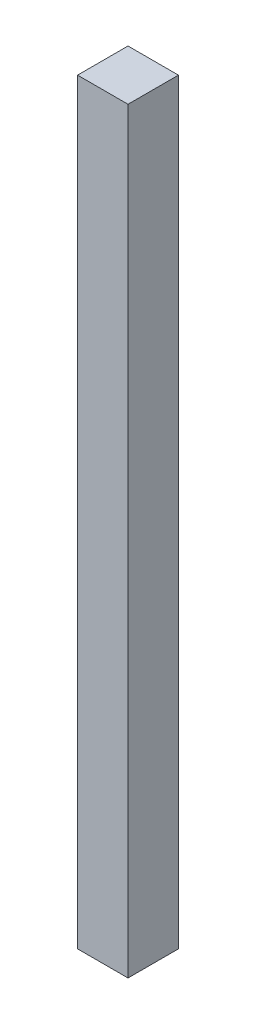
from build123d import *

# Parameters (mm, degrees)
ESQUISSE1_W        = 10
ESQUISSE1_H        = 10
BOSS_EXTRU_1_DEPTH = 150


with BuildPart() as part:
    # Esquisse1 → Boss.-Extru.1 (new body)
    with BuildSketch(Plane(origin=(0, 0, 0), x_dir=(1, 0, 0), z_dir=(0, 1, 0))):
        with Locations((5, 5)):
            Rectangle(ESQUISSE1_W, ESQUISSE1_H)
    extrude(amount=BOSS_EXTRU_1_DEPTH)


solid = part.part
